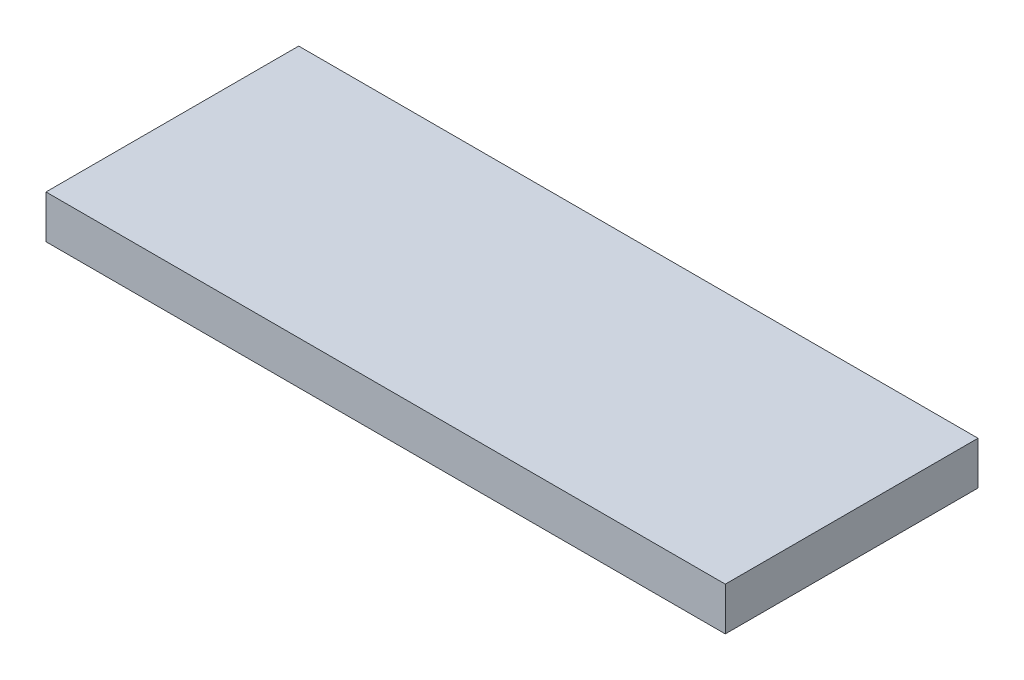
from build123d import *

# Parameters (mm, degrees)
SKETCH1_W           = 50
SKETCH1_H           = 18.6
BOSS_EXTRUDE1_DEPTH = 3.175


with BuildPart() as part:
    # Sketch1 → Boss-Extrude1 (new body)
    with BuildSketch(Plane(origin=(0, 0, 0), x_dir=(1, 0, 0), z_dir=(0, 1, 0))):
        with Locations((25, 9.3)):
            Rectangle(SKETCH1_W, SKETCH1_H)
    extrude(amount=BOSS_EXTRUDE1_DEPTH)


solid = part.part
